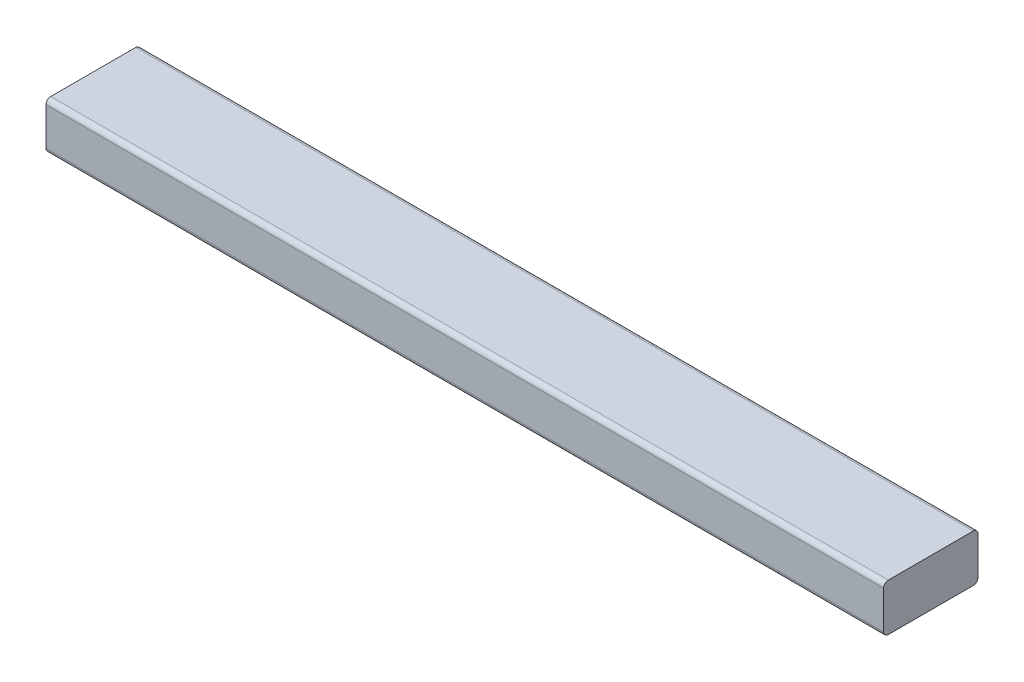
from build123d import *

# Parameters (mm, degrees)
SKETCH3_W           = 901.6
SKETCH3_H           = 101.6
BOSS_EXTRUDE3_DEPTH = 50.8
FILLET1_R           = 5.08


with BuildPart() as part:
    # Sketch3 → Boss-Extrude3 (new body)
    with BuildSketch(Plane(origin=(0, -12.7, 0), x_dir=(-1, 0, 0), z_dir=(0, -1, 0))):
        with Locations((-2263.5, -338.5)):
            Rectangle(SKETCH3_W, SKETCH3_H)
    extrude(amount=-BOSS_EXTRUDE3_DEPTH)

    # Fillet1
    fillet1_edges = [part.edges().sort_by_distance(p)[0] for p in [
        (2263.5, 38.1, 389.3),
        (2263.5, -12.7, 389.3),
        (2263.5, -12.7, 287.7),
        (2263.5, 38.1, 287.7),
    ]]
    fillet(fillet1_edges, radius=FILLET1_R)


solid = part.part
